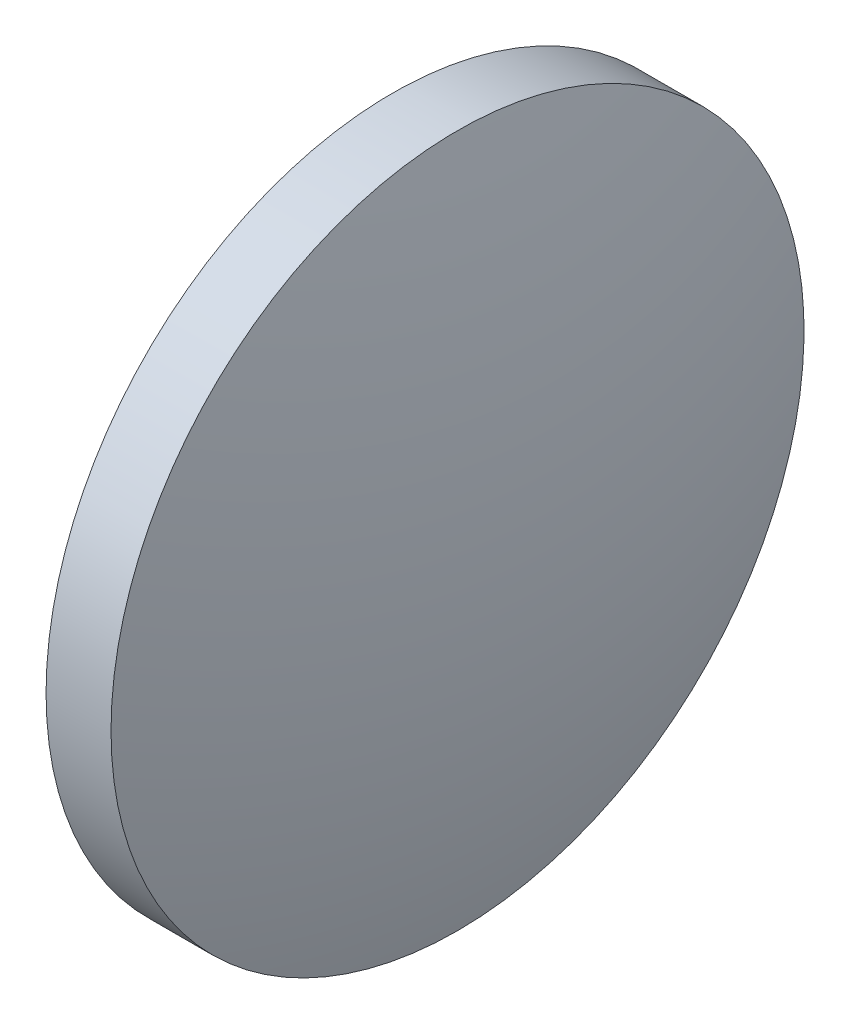
from build123d import *


with BuildPart() as part:
    # 草图1 → 旋转1 (revolve)
    with BuildSketch(Plane.XY, mode=Mode.PRIVATE) as revolve_1_sk:
        with BuildLine():
            Line((608.826461458, 205.970438783), (608.826461458, 213.970438783))
            Line((608.826461458, 213.970438783), (610.326461458, 213.970438783))
            ThreePointArc((610.326461458, 213.970438783), (611.172566263, 210.010144836), (611.456461458, 205.970438783))
            Line((611.456461458, 205.970438783), (608.826461458, 205.970438783))
        make_face()
    revolve(revolve_1_sk.sketch.rotate(Axis((606.545514054, 205.970438783, 0), (1, 0, 0)), 180), axis=Axis((606.545514054, 205.970438783, 0), (1, 0, 0)))  # turned: the seam where the file's is


solid = part.part
